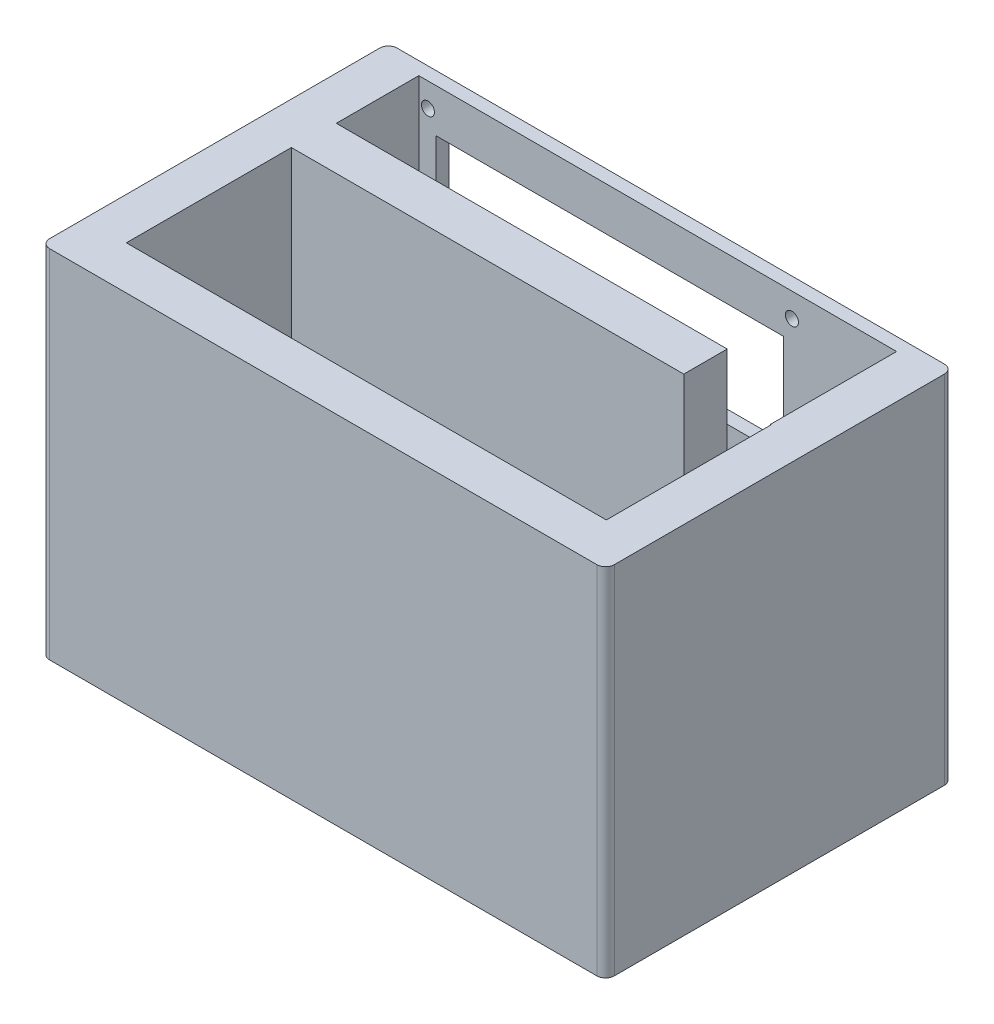
from build123d import *

# Parameters (mm, degrees)
ESQUISSE1_W              = 130
ESQUISSE1_H              = 80
BOSS_EXTRU_1_DEPTH       = 82
ESQUISSE4_W              = 110
ESQUISSE4_H              = 19
ENL_V_MAT_EXTRU_1_DEPTH  = 77
ESQUISSE7_W              = 80
ESQUISSE7_H              = 24
ENL_V_MAT_EXTRU_2_DEPTH  = 5
ESQUISSE8_W              = 80
ESQUISSE8_H              = 24
ENL_V_MAT_EXTRU_3_DEPTH  = 5
CONG_1_R                 = 2
ESQUISSE9_W              = 110.509811946
ESQUISSE9_H              = 38
ENL_V_MAT_EXTRU_4_DEPTH  = 77
ESQUISSE10_W             = 20
ESQUISSE10_H             = 10
ENL_V_MAT_EXTRU_5_DEPTH  = 77
ESQUISSE11_R             = 1.5
ENL_V_MAT_EXTRU_6_DEPTH  = 3
ESQUISSE12_R             = 1.5
ENL_V_MAT_EXTRU_7_DEPTH  = 3
ESQUISSE13_R             = 1.5
ENL_V_MAT_EXTRU_8_DEPTH  = 3
ESQUISSE14_R             = 1.5
ENL_V_MAT_EXTRU_11_DEPTH = 3


with BuildPart() as part:
    # Esquisse1 → Boss.-Extru.1 (new body)
    with BuildSketch(Plane(origin=(0, 0, 0), x_dir=(1, 0, 0), z_dir=(0, 1, 0))):
        Rectangle(ESQUISSE1_W, ESQUISSE1_H)
    extrude(amount=BOSS_EXTRU_1_DEPTH)

    # Esquisse4 → Enlèv. mat.-Extru.1 (cut)
    with BuildSketch(Plane(origin=(0, 82, 0), x_dir=(1, 0, 0), z_dir=(0, 1, 0))):
        with Locations((0, 27.5)):
            Rectangle(ESQUISSE4_W, ESQUISSE4_H)
    extrude(amount=-ENL_V_MAT_EXTRU_1_DEPTH, mode=Mode.SUBTRACT)

    # Esquisse7 → Enlèv. mat.-Extru.2 (cut)
    with BuildSketch(Plane(origin=(0, 0, -40), x_dir=(-1, 0, 0), z_dir=(0, 0, -1))):
        with Locations((11, 23)):
            Rectangle(ESQUISSE7_W, ESQUISSE7_H)
    extrude(amount=-ENL_V_MAT_EXTRU_2_DEPTH, mode=Mode.SUBTRACT)

    # Esquisse8 → Enlèv. mat.-Extru.3 (cut)
    with BuildSketch(Plane(origin=(0, 0, -40), x_dir=(-1, 0, 0), z_dir=(0, 0, -1))):
        with Locations((11, 60)):
            Rectangle(ESQUISSE8_W, ESQUISSE8_H)
    extrude(amount=-ENL_V_MAT_EXTRU_3_DEPTH, mode=Mode.SUBTRACT)

    # Congé1
    cong_1_edges = [part.edges().sort_by_distance(p)[0] for p in [
        (-65, 41, -40),
        (65, 41, -40),
        (65, 41, 40),
        (-65, 41, 40),
    ]]
    fillet(cong_1_edges, radius=CONG_1_R)

    # Esquisse9 → Enlèv. mat.-Extru.4 (cut)
    with BuildSketch(Plane(origin=(0, 82, 0), x_dir=(1, 0, 0), z_dir=(0, 1, 0))):
        with Locations((-0.082965324, -11)):
            Rectangle(ESQUISSE9_W, ESQUISSE9_H)
    extrude(amount=-ENL_V_MAT_EXTRU_4_DEPTH, mode=Mode.SUBTRACT)

    # Esquisse10 → Enlèv. mat.-Extru.5 (cut)
    with BuildSketch(Plane(origin=(0, 82, 0), x_dir=(1, 0, 0), z_dir=(0, 1, 0))):
        with Locations((45, 13)):
            Rectangle(ESQUISSE10_W, ESQUISSE10_H)
    extrude(amount=-ENL_V_MAT_EXTRU_5_DEPTH, mode=Mode.SUBTRACT)

    # Esquisse11 → Enlèv. mat.-Extru.6 (cut)
    with BuildSketch(Plane(origin=(0, 0, -40), x_dir=(-1, 0, 0), z_dir=(0, 0, -1))):
        with Locations((-30.9, 39.5)):
            Circle(ESQUISSE11_R)
    enl_v_mat_extru_6 = extrude(amount=-ENL_V_MAT_EXTRU_6_DEPTH, mode=Mode.SUBTRACT)

    # Esquisse12 → Enlèv. mat.-Extru.7 (cut)
    with BuildSketch(Plane(origin=(0, 0, -40), x_dir=(-1, 0, 0), z_dir=(0, 0, -1))):
        with Locations((-30.9, 45.5)):
            Circle(ESQUISSE12_R)
    enl_v_mat_extru_7 = extrude(amount=-ENL_V_MAT_EXTRU_7_DEPTH, mode=Mode.SUBTRACT)

    # Symétrie1: Enlèv. mat.-Extru.6, Enlèv. mat.-Extru.7 across plane
    add(enl_v_mat_extru_6.mirror(Plane(origin=(-11, 0, 0), x_dir=(0, 0, 1), z_dir=(1, 0, 0))), mode=Mode.SUBTRACT)
    add(enl_v_mat_extru_7.mirror(Plane(origin=(-11, 0, 0), x_dir=(0, 0, 1), z_dir=(1, 0, 0))), mode=Mode.SUBTRACT)

    # Esquisse13 → Enlèv. mat.-Extru.8 (cut)
    with BuildSketch(Plane(origin=(0, 0, -40), x_dir=(-1, 0, 0), z_dir=(0, 0, -1))):
        with Locations((-30.9, 76.5)):
            Circle(ESQUISSE13_R)
    enl_v_mat_extru_8 = extrude(amount=-ENL_V_MAT_EXTRU_8_DEPTH, mode=Mode.SUBTRACT)

    # Symétrie2: Enlèv. mat.-Extru.8 across plane
    add(enl_v_mat_extru_8.mirror(Plane(origin=(-11, 0, 0), x_dir=(0, 0, 1), z_dir=(1, 0, 0))), mode=Mode.SUBTRACT)

    # Esquisse14 → Enlèv. mat.-Extru.11 (cut)
    with BuildSketch(Plane(origin=(0, 0, -40), x_dir=(-1, 0, 0), z_dir=(0, 0, -1))):
        with Locations((-30.9, 8.5)):
            Circle(ESQUISSE14_R)
    enl_v_mat_extru_11 = extrude(amount=-ENL_V_MAT_EXTRU_11_DEPTH, mode=Mode.SUBTRACT)

    # Symétrie3: Enlèv. mat.-Extru.11 across plane
    add(enl_v_mat_extru_11.mirror(Plane(origin=(-11, 0, 0), x_dir=(0, 0, 1), z_dir=(1, 0, 0))), mode=Mode.SUBTRACT)


solid = part.part
